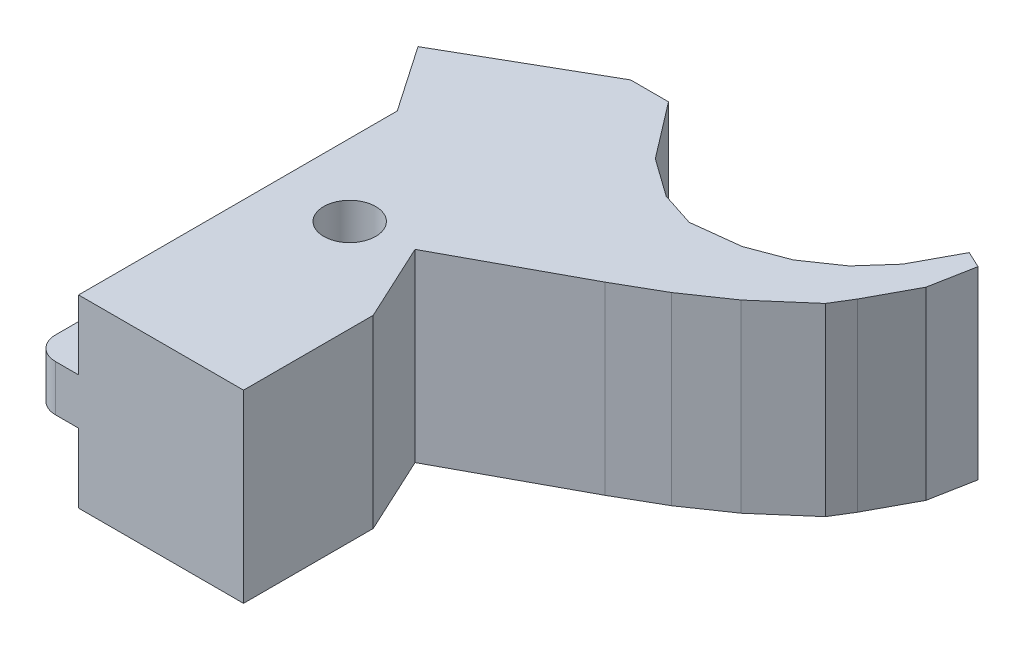
from build123d import *

# Parameters (mm, degrees)
SKETCH1_R           = 2.25
BOSS_EXTRUDE1_DEPTH = 16
SKETCH4_W           = 8
SKETCH4_H           = 4
BOSS_EXTRUDE3_DEPTH = 4
CUT_EXTRUDE2_DEPTH  = 6


with BuildPart() as part:
    # Sketch1 → Boss-Extrude1 (new body)
    with BuildSketch(Plane(origin=(0, 0, 0), x_dir=(1, 0, 0), z_dir=(0, 1, 0))):
        Polygon((0, 0), (14.292346673, 0), (14.292346673, 11.238609792), (11.156143946, 17.994963368), (21.835642334, 23.763983363), (25.517809154, 25.875036511), (29.085232636, 28.322878493), (32.990082947, 31.710975059), (34.049112719, 33.434353148), (36.126472393, 37.292437563), (36.843322223, 41.087524896), (35.409622564, 41.762207089), (33.385918935, 38.003772992), (31.21539446, 35.564385481), (28.344844636, 33.594713978), (25.109272652, 32.382219348), (21.002122002, 31.901327051), (18.052032719, 32.863111645), (14.769017999, 35.202837629), (11.063605769, 40.049098317), (7.779911083, 40.049098317), (-3.927764052, 33.33687542), (0, 27.612650649), align=None)
        with Locations((6.23417855, 17.258888852)):
            Circle(SKETCH1_R, mode=Mode.SUBTRACT)
    extrude(amount=BOSS_EXTRUDE1_DEPTH)

    # Sketch4 → Boss-Extrude3 (add)
    with BuildSketch(Plane.ZY):
        with Locations((-4, 8)):
            Rectangle(SKETCH4_W, SKETCH4_H)
    extrude(amount=BOSS_EXTRUDE3_DEPTH)

    # Sketch5 → Cut-Extrude2 (cut)
    with BuildSketch(Plane(origin=(0, 10, 0), x_dir=(1, 0, 0), z_dir=(0, 1, 0))):
        with BuildLine():
            Line((-2, 8), (-2, 4.450866614))
            ThreePointArc((-2, 4.450866614), (-1.853553391, 4.097313224), (-1.5, 3.950866614))
            Line((-1.5, 3.950866614), (-0.5, 3.950866614))
            ThreePointArc((-0.5, 3.950866614), (-0.146446609, 4.097313224), (0, 4.450866614))
            Line((0, 4.450866614), (0, 8))
            Line((0, 8), (-2, 8))
        make_face()
        with BuildLine():
            Line((-4, 2), (-4, 0))
            Line((-4, 0), (-2, 0))
            ThreePointArc((-2, 0), (-3.414213562, 0.585786438), (-4, 2))
        make_face()
    extrude(amount=-CUT_EXTRUDE2_DEPTH, mode=Mode.SUBTRACT)


solid = part.part
